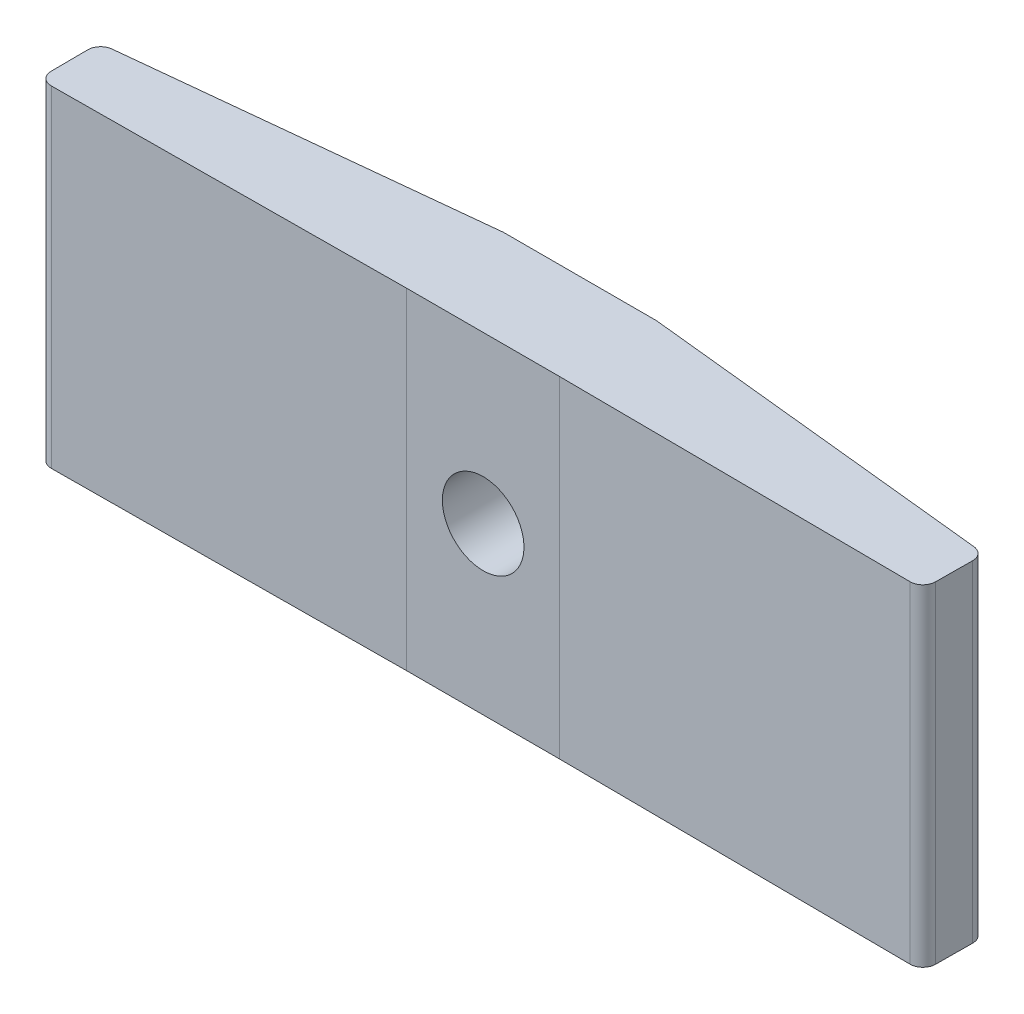
from build123d import *

# Parameters (mm, degrees)
BOSS_EXTRUDE1_DEPTH       = 13
FILLET2_R                 = 0.5
SKETCH2_R                 = 1.6
CUT_EXTRUDE1_DEPTH        = 4.896527904
REVISION_INDICATION_DEPTH = 0.4


with BuildPart() as part:
    # Sketch1 → Boss-Extrude1 (new body)
    with BuildSketch(Plane(origin=(0, 0, 0), x_dir=(1, 0, 0), z_dir=(0, 1, 0))):
        Polygon((20.35, 0.1), (14.35, 0.1), (0, 0), (-0.016724739, 2.4), (14.35, 3.9), (20.35, 3.9), (34.716724739, 2.4), (34.7, 0), align=None)
    extrude(amount=BOSS_EXTRUDE1_DEPTH)

    # Fillet2
    fillet2_edges = [part.edges().sort_by_distance(p)[0] for p in [
        (-0.016724739, 6.5, -2.4),
        (34.716724739, 6.5, -2.4),
        (34.7, 6.5, 0),
        (0, 6.5, 0),
    ]]
    fillet(fillet2_edges, radius=FILLET2_R)

    # Sketch2 → Cut-Extrude1 (cut, through all)
    with BuildSketch(Plane(origin=(0, 0, -3.9), x_dir=(-1, 0, 0), z_dir=(0, 0, -1))):
        with Locations((-17.35, 6.5)):
            Circle(SKETCH2_R)
    extrude(amount=-CUT_EXTRUDE1_DEPTH, mode=Mode.SUBTRACT)

    # Sketch5 → revision indication (add)
    with BuildSketch(Plane(origin=(-0.248057274, 0, -2.375847049), x_dir=(-0.994593653, 0, 0.103843465), z_dir=(-0.103843465, 0, -0.994593653))):
        with BuildLine():
            add(Edge.make_bspline(
                [(-1.785308798, 1.976923077), (-1.749947985, 1.974821832), (-1.680627244, 1.970702586), (-1.580407683, 1.942442049), (-1.489703086, 1.892261337), (-1.40890887, 1.825381725), (-1.342312834, 1.744291021), (-1.290343795, 1.654309873), (-1.262329436, 1.553251269), (-1.258240196, 1.483528859), (-1.256142132, 1.44775641)],
                knots=[0, 0, 0, 0, 0.000106068, 0.000207934, 0.000309251, 0.000414952, 0.000520654, 0.000622584, 0.00072445, 0.000831784, 0.000831784, 0.000831784, 0.000831784], degree=3))
            add(Edge.make_bspline(
                [(-1.256142132, 1.44775641), (-1.258311293, 1.412843512), (-1.262588847, 1.343995789), (-1.290279579, 1.243699421), (-1.342708899, 1.153662038), (-1.408449529, 1.071471016), (-1.489723058, 1.004449722), (-1.580622123, 0.954695939), (-1.680391977, 0.924411918), (-1.749908735, 0.920554208), (-1.785308798, 0.918589744)],
                knots=[0, 0, 0, 0, 0.000104802, 0.000206668, 0.000308598, 0.000415282, 0.000520984, 0.0006223, 0.000724523, 0.000830591, 0.000830591, 0.000830591, 0.000830591], degree=3))
            add(Edge.make_bspline(
                [(-1.785308798, 0.918589744), (-1.82073437, 0.920483127), (-1.889894366, 0.924179507), (-1.989291812, 0.955317742), (-2.080744455, 1.003983162), (-2.162002161, 1.071595984), (-2.228293388, 1.153239101), (-2.278413725, 1.244319503), (-2.308512996, 1.343708683), (-2.312471536, 1.412786963), (-2.314475465, 1.44775641)],
                knots=[0, 0, 0, 0, 0.000106068, 0.000207073, 0.000309509, 0.000415211, 0.000521895, 0.000623212, 0.000725435, 0.000830237, 0.000830237, 0.000830237, 0.000830237], degree=3))
            add(Edge.make_bspline(
                [(-2.314475465, 1.44775641), (-2.312548513, 1.483587428), (-2.308786377, 1.553543092), (-2.278350536, 1.653690044), (-2.228682266, 1.744709926), (-2.161543907, 1.825258007), (-2.080764113, 1.892726399), (-1.989512426, 1.941829667), (-1.889654975, 1.970931558), (-1.820694086, 1.974891267), (-1.785308798, 1.976923077)],
                knots=[0, 0, 0, 0, 0.000107334, 0.000209557, 0.000310874, 0.000416575, 0.000522277, 0.000624713, 0.000725357, 0.000831425, 0.000831425, 0.000831425, 0.000831425], degree=3))
        make_face()
        with BuildLine():
            add(Edge.make_bspline(
                [(-4.146206234, 1.976923077), (-4.110845421, 1.974821832), (-4.04152468, 1.970702586), (-3.941305118, 1.942442049), (-3.850600522, 1.892261337), (-3.769806306, 1.825381725), (-3.70321027, 1.744291021), (-3.651241231, 1.654309873), (-3.623226872, 1.553251269), (-3.619137632, 1.483528859), (-3.617039568, 1.44775641)],
                knots=[0, 0, 0, 0, 0.000106068, 0.000207934, 0.000309251, 0.000414952, 0.000520654, 0.000622584, 0.00072445, 0.000831784, 0.000831784, 0.000831784, 0.000831784], degree=3))
            add(Edge.make_bspline(
                [(-3.617039568, 1.44775641), (-3.619208729, 1.412843512), (-3.623486283, 1.343995789), (-3.651177015, 1.243699421), (-3.703606335, 1.153662038), (-3.769346965, 1.071471016), (-3.850620494, 1.004449722), (-3.941519559, 0.954695939), (-4.041289413, 0.924411918), (-4.110806171, 0.920554208), (-4.146206234, 0.918589744)],
                knots=[0, 0, 0, 0, 0.000104802, 0.000206668, 0.000308598, 0.000415282, 0.000520984, 0.0006223, 0.000724523, 0.000830591, 0.000830591, 0.000830591, 0.000830591], degree=3))
            add(Edge.make_bspline(
                [(-4.146206234, 0.918589744), (-4.181631806, 0.920483127), (-4.250791802, 0.924179507), (-4.350189248, 0.955317742), (-4.441641891, 1.003983162), (-4.522899597, 1.071595984), (-4.589190824, 1.153239101), (-4.639311161, 1.244319503), (-4.669410431, 1.343708683), (-4.673368972, 1.412786963), (-4.675372901, 1.44775641)],
                knots=[0, 0, 0, 0, 0.000106068, 0.000207073, 0.000309509, 0.000415211, 0.000521895, 0.000623212, 0.000725435, 0.000830237, 0.000830237, 0.000830237, 0.000830237], degree=3))
            add(Edge.make_bspline(
                [(-4.675372901, 1.44775641), (-4.673445949, 1.483587428), (-4.669683813, 1.553543092), (-4.639247972, 1.653690044), (-4.589579702, 1.744709926), (-4.522441343, 1.825258007), (-4.441661549, 1.892726399), (-4.350409862, 1.941829667), (-4.25055241, 1.970931558), (-4.181591522, 1.974891267), (-4.146206234, 1.976923077)],
                knots=[0, 0, 0, 0, 0.000107334, 0.000209557, 0.000310874, 0.000416575, 0.000522277, 0.000624713, 0.000725357, 0.000831425, 0.000831425, 0.000831425, 0.000831425], degree=3))
        make_face()
        with BuildLine():
            add(Edge.make_bspline(
                [(-6.50710367, 1.976923077), (-6.471742857, 1.974821832), (-6.402422116, 1.970702586), (-6.302202554, 1.942442049), (-6.211497957, 1.892261337), (-6.130703742, 1.825381725), (-6.064107706, 1.744291021), (-6.012138667, 1.654309873), (-5.984124308, 1.553251269), (-5.980035068, 1.483528859), (-5.977937003, 1.44775641)],
                knots=[0, 0, 0, 0, 0.000106068, 0.000207934, 0.000309251, 0.000414952, 0.000520654, 0.000622584, 0.00072445, 0.000831784, 0.000831784, 0.000831784, 0.000831784], degree=3))
            add(Edge.make_bspline(
                [(-5.977937003, 1.44775641), (-5.980106165, 1.412843512), (-5.984383719, 1.343995789), (-6.012074451, 1.243699421), (-6.064503771, 1.153662038), (-6.130244401, 1.071471016), (-6.21151793, 1.004449722), (-6.302416994, 0.954695939), (-6.402186849, 0.924411918), (-6.471703607, 0.920554208), (-6.50710367, 0.918589744)],
                knots=[0, 0, 0, 0, 0.000104802, 0.000206668, 0.000308598, 0.000415282, 0.000520984, 0.0006223, 0.000724523, 0.000830591, 0.000830591, 0.000830591, 0.000830591], degree=3))
            add(Edge.make_bspline(
                [(-6.50710367, 0.918589744), (-6.542529242, 0.920483127), (-6.611689237, 0.924179507), (-6.711086684, 0.955317742), (-6.802539327, 1.003983162), (-6.883797033, 1.071595984), (-6.95008826, 1.153239101), (-7.000208597, 1.244319503), (-7.030307867, 1.343708683), (-7.034266408, 1.412786963), (-7.036270337, 1.44775641)],
                knots=[0, 0, 0, 0, 0.000106068, 0.000207073, 0.000309509, 0.000415211, 0.000521895, 0.000623212, 0.000725435, 0.000830237, 0.000830237, 0.000830237, 0.000830237], degree=3))
            add(Edge.make_bspline(
                [(-7.036270337, 1.44775641), (-7.034343385, 1.483587428), (-7.030581249, 1.553543092), (-7.000145408, 1.653690044), (-6.950477138, 1.744709926), (-6.883338779, 1.825258007), (-6.802558985, 1.892726399), (-6.711307298, 1.941829667), (-6.611449846, 1.970931558), (-6.542488958, 1.974891267), (-6.50710367, 1.976923077)],
                knots=[0, 0, 0, 0, 0.000107334, 0.000209557, 0.000310874, 0.000416575, 0.000522277, 0.000624713, 0.000725357, 0.000831425, 0.000831425, 0.000831425, 0.000831425], degree=3))
        make_face()
        with BuildLine():
            add(Edge.make_bspline(
                [(-8.868001106, 1.976923077), (-8.832640293, 1.974821832), (-8.763319552, 1.970702586), (-8.66309999, 1.942442049), (-8.572395393, 1.892261337), (-8.491601178, 1.825381725), (-8.425005142, 1.744291021), (-8.373036103, 1.654309873), (-8.345021744, 1.553251269), (-8.340932504, 1.483528859), (-8.338834439, 1.44775641)],
                knots=[0, 0, 0, 0, 0.000106068, 0.000207934, 0.000309251, 0.000414952, 0.000520654, 0.000622584, 0.00072445, 0.000831784, 0.000831784, 0.000831784, 0.000831784], degree=3))
            add(Edge.make_bspline(
                [(-8.338834439, 1.44775641), (-8.341003601, 1.412843512), (-8.345281155, 1.343995789), (-8.372971887, 1.243699421), (-8.425401207, 1.153662038), (-8.491141837, 1.071471016), (-8.572415366, 1.004449722), (-8.66331443, 0.954695939), (-8.763084284, 0.924411918), (-8.832601042, 0.920554208), (-8.868001106, 0.918589744)],
                knots=[0, 0, 0, 0, 0.000104802, 0.000206668, 0.000308598, 0.000415282, 0.000520984, 0.0006223, 0.000724523, 0.000830591, 0.000830591, 0.000830591, 0.000830591], degree=3))
            add(Edge.make_bspline(
                [(-8.868001106, 0.918589744), (-8.903426678, 0.920483127), (-8.972586673, 0.924179507), (-9.07198412, 0.955317742), (-9.163436763, 1.003983162), (-9.244694469, 1.071595984), (-9.310985696, 1.153239101), (-9.361106033, 1.244319503), (-9.391205303, 1.343708683), (-9.395163844, 1.412786963), (-9.397167773, 1.44775641)],
                knots=[0, 0, 0, 0, 0.000106068, 0.000207073, 0.000309509, 0.000415211, 0.000521895, 0.000623212, 0.000725435, 0.000830237, 0.000830237, 0.000830237, 0.000830237], degree=3))
            add(Edge.make_bspline(
                [(-9.397167773, 1.44775641), (-9.395240821, 1.483587428), (-9.391478685, 1.553543092), (-9.361042844, 1.653690044), (-9.311374574, 1.744709926), (-9.244236214, 1.825258007), (-9.16345642, 1.892726399), (-9.072204734, 1.941829667), (-8.972347282, 1.970931558), (-8.903386394, 1.974891267), (-8.868001106, 1.976923077)],
                knots=[0, 0, 0, 0, 0.000107334, 0.000209557, 0.000310874, 0.000416575, 0.000522277, 0.000624713, 0.000725357, 0.000831425, 0.000831425, 0.000831425, 0.000831425], degree=3))
        make_face()
    extrude(amount=REVISION_INDICATION_DEPTH)


solid = part.part
